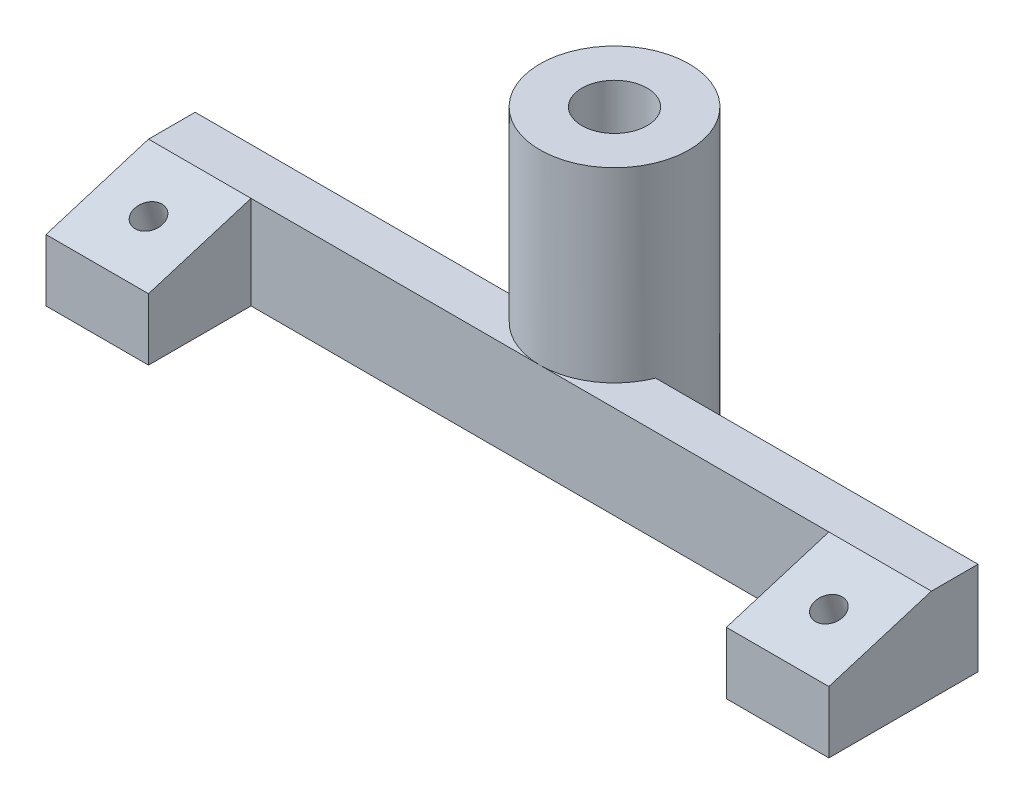
from build123d import *

# Parameters (mm, degrees)
EXTRUDE_1_DEPTH     = 10
CUT_EXTRUDE_4_DEPTH = 85
SKETCH_6_R          = 1.5
CUT_EXTRUDE_5_DEPTH = 12.024906083
SKETCH_7_R          = 3.25
CUT_EXTRUDE_6_DEPTH = 8.024906083
SKETCH_8_R          = 8
EXTRUDE_2_DEPTH     = 30
SKETCH_9_R          = 3.5
CUT_EXTRUDE_7_DEPTH = 30
SKETCH_10_R         = 5.25
CUT_EXTRUDE_8_DEPTH = 24


with BuildPart() as part:
    # 草图1 → 凸台-拉伸1 (new body)
    with BuildSketch(Plane(origin=(0, 0, 0), x_dir=(1, 0, 0), z_dir=(0, 1, 0))):
        Polygon((-42, 5.5), (-42, 10.5), (42, 10.5), (42, 5.5), (42, -5.5), (31, -5.5), (31, 5.5), (-31, 5.5), (-31, -5.5), (-42, -5.5), align=None)
    extrude(amount=EXTRUDE_1_DEPTH)

    # 草图5 → 切除-拉伸4 (cut, through all)
    with BuildSketch(Plane.ZY.offset(42)):
        Polygon((-5.5, 10), (5.5, 6.636962504), (5.5, 10), align=None)
    extrude(amount=-CUT_EXTRUDE_4_DEPTH, mode=Mode.SUBTRACT)

    # 草图6 → 切除-拉伸5 (cut, through all)
    with BuildSketch(Plane(origin=(0, 12.692999356, -14.308403996), x_dir=(1, 0, 0), z_dir=(0, -0.956304756, -0.292371705))):
        with Locations((-36.5, 14.962180107)):
            Circle(SKETCH_6_R)
        with Locations((36.5, 14.962180107)):
            Circle(SKETCH_6_R)
    extrude(amount=CUT_EXTRUDE_5_DEPTH, mode=Mode.SUBTRACT)

    # 草图7 → 切除-拉伸6 (cut, through all)
    with BuildSketch(Plane(origin=(0, 3.782188354, 1.156331023), x_dir=(1, 0, 0), z_dir=(0, 0.956304756, 0.292371705))):
        with Locations((36.5, 2.432088544)):
            Circle(SKETCH_7_R)
        with Locations((-36.5, 2.432088544)):
            Circle(SKETCH_7_R)
    extrude(amount=-CUT_EXTRUDE_6_DEPTH, mode=Mode.SUBTRACT)

    # 草图8 → 凸台-拉伸2 (add)
    with BuildSketch(Plane.XZ):
        with Locations((0, -13.5)):
            Circle(SKETCH_8_R)
    extrude(amount=-EXTRUDE_2_DEPTH)

    # 草图9 → 切除-拉伸7 (cut)
    with BuildSketch(Plane(origin=(0, 30, 0), x_dir=(1, 0, 0), z_dir=(0, 1, 0))):
        with Locations((0, 13.5)):
            Circle(SKETCH_9_R)
    extrude(amount=-CUT_EXTRUDE_7_DEPTH, mode=Mode.SUBTRACT)

    # 草图10 → 切除-拉伸8 (cut)
    with BuildSketch(Plane.XZ):
        with Locations((0, -13.5)):
            Circle(SKETCH_10_R)
    extrude(amount=-CUT_EXTRUDE_8_DEPTH, mode=Mode.SUBTRACT)


solid = part.part
